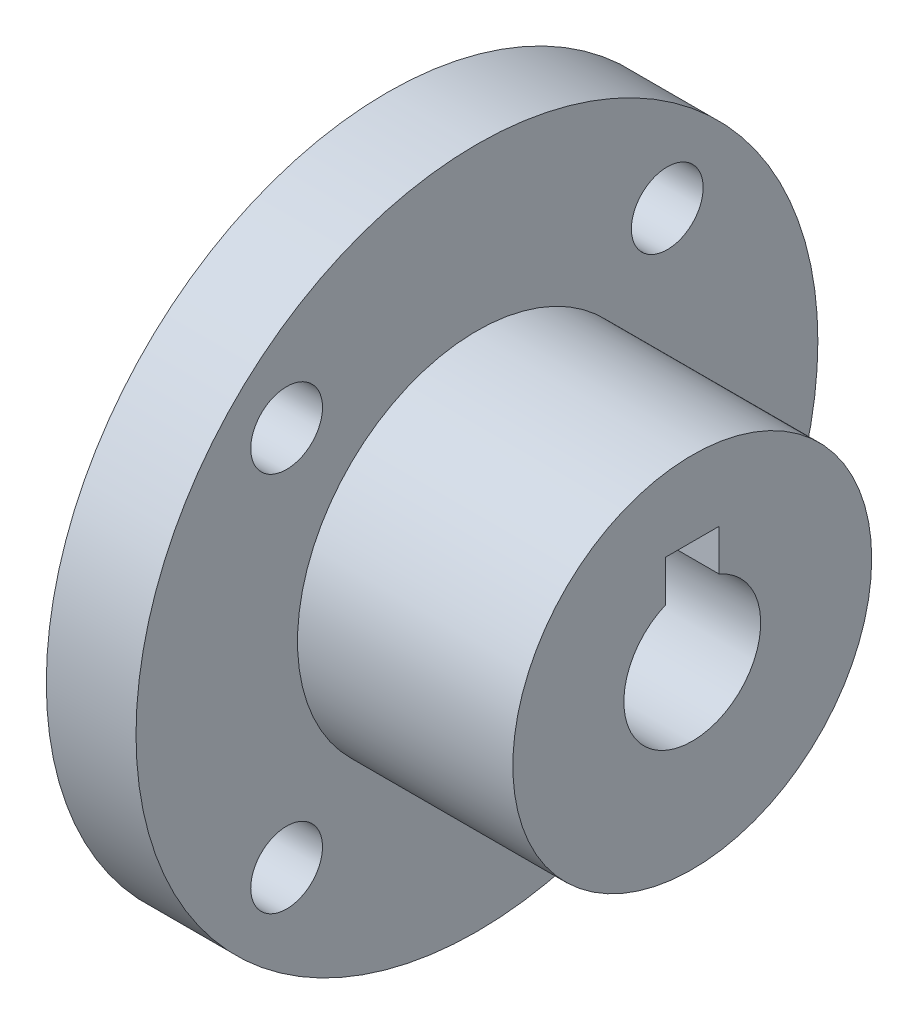
from build123d import *

# Parameters (mm, degrees)
SKETCH1_R        = 10
SMALLRING_DEPTH  = 12
SKETCH4_R        = 19
SKETCH4_R_2      = 2
BIGRING_DEPTH    = 5
SKETCH42_R       = 3.8125
SHAFT_HOLE_DEPTH = 17
SKETCH43_W       = 3
SKETCH43_H       = 4
KEYWAY_DEPTH     = 17


with BuildPart() as part:
    # Sketch1 → SmallRing (new body)
    with BuildSketch(Plane(origin=(0, 0, 0), x_dir=(0, 0, -1), z_dir=(1, 0, 0))):
        Circle(SKETCH1_R)
    extrude(amount=SMALLRING_DEPTH)

    # Sketch4 → BigRing (add)
    with BuildSketch(Plane.ZY):
        Circle(SKETCH4_R)
        with Locations((-10.606601718, 10.606601718)):
            Circle(SKETCH4_R_2, mode=Mode.SUBTRACT)
        with Locations((10.606601718, 10.606601718)):
            Circle(SKETCH4_R_2, mode=Mode.SUBTRACT)
        with Locations((10.606601718, -10.606601718)):
            Circle(SKETCH4_R_2, mode=Mode.SUBTRACT)
        with Locations((-10.606601718, -10.606601718)):
            Circle(SKETCH4_R_2, mode=Mode.SUBTRACT)
    extrude(amount=BIGRING_DEPTH)

    # Sketch42 → Shaft Hole (cut)
    with BuildSketch(Plane(origin=(12, 0, 0), x_dir=(0, 0, -1), z_dir=(1, 0, 0))):
        Circle(SKETCH42_R)
    extrude(amount=-SHAFT_HOLE_DEPTH, mode=Mode.SUBTRACT)

    # Sketch43 → KeyWay (cut)
    with BuildSketch(Plane(origin=(12, 0, 0), x_dir=(0, 0, -1), z_dir=(1, 0, 0))):
        with Locations((0, 3.8125)):
            Rectangle(SKETCH43_W, SKETCH43_H)
    extrude(amount=-KEYWAY_DEPTH, mode=Mode.SUBTRACT)


solid = part.part
